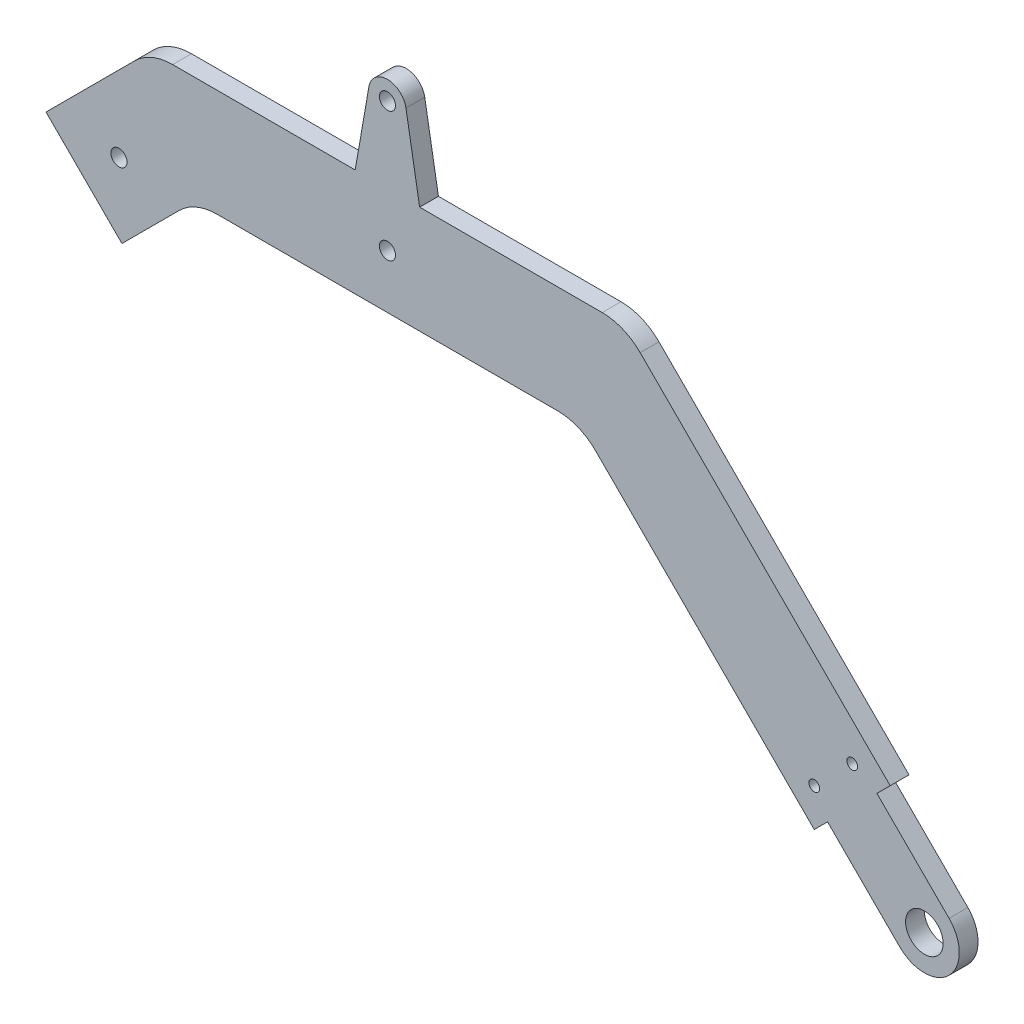
from build123d import *

# Parameters (mm, degrees)
SKETCH5_R           = 1
SKETCH5_R_2         = 3.5
SKETCH5_R_3         = 1.5
BOSS_EXTRUDE1_DEPTH = 3.5
FILLET1_R           = 10


with BuildPart() as part:
    # Sketch5 → Boss-Extrude1 (new body)
    with BuildSketch(Plane.XY):
        with BuildLine():
            Line((91.161165235, 18.03122292), (104.596194078, 4.596194078))
            ThreePointArc((104.596194078, 4.596194078), (104.596194078, -4.596194078), (95.403805922, -4.596194078))
            Line((95.403805922, -4.596194078), (81.96877708, 8.838834765))
            Line((81.96877708, 8.838834765), (79.493903346, 6.363961031))
            Line((79.493903346, 6.363961031), (35.857864376, 50))
            Line((35.857864376, 50), (-35.857864376, 50))
            Line((-35.857864376, 50), (-49.445436483, 36.412427894))
            Line((-49.445436483, 36.412427894), (-63.587572106, 50.554563517))
            Line((-63.587572106, 50.554563517), (-44.142135624, 70))
            Line((-44.142135624, 70), (-6, 70))
            Line((-6, 70), (-3.448564481, 84.717831932))
            ThreePointArc((-3.448564481, 84.717831932), (0, 87.62), (3.448564481, 84.717831932))
            Line((3.448564481, 84.717831932), (6, 70))
            Line((6, 70), (44.142135624, 70))
            Line((44.142135624, 70), (93.636038969, 20.506096654))
            Line((93.636038969, 20.506096654), (91.161165235, 18.03122292))
        make_face()
        with Locations((86.564971157, 20.506096654)):
            Circle(SKETCH5_R, mode=Mode.SUBTRACT)
        with Locations((79.493903346, 13.435028843)):
            Circle(SKETCH5_R, mode=Mode.SUBTRACT)
        with Locations((100, 0)):
            Circle(SKETCH5_R_2, mode=Mode.SUBTRACT)
        with Locations((0, 84.12)):
            Circle(SKETCH5_R_3, mode=Mode.SUBTRACT)
        with Locations((0, 60)):
            Circle(SKETCH5_R_3, mode=Mode.SUBTRACT)
        with Locations((-50, 50)):
            Circle(SKETCH5_R_3, mode=Mode.SUBTRACT)
    extrude(amount=BOSS_EXTRUDE1_DEPTH)

    # Fillet1
    fillet1_edges = [part.edges().sort_by_distance(p)[0] for p in [
        (44.142135624, 70, 1.75),
        (35.857864376, 50, 1.75),
        (-35.857864376, 50, 1.75),
        (-44.142135624, 70, 1.75),
    ]]
    fillet(fillet1_edges, radius=FILLET1_R)


solid = part.part
